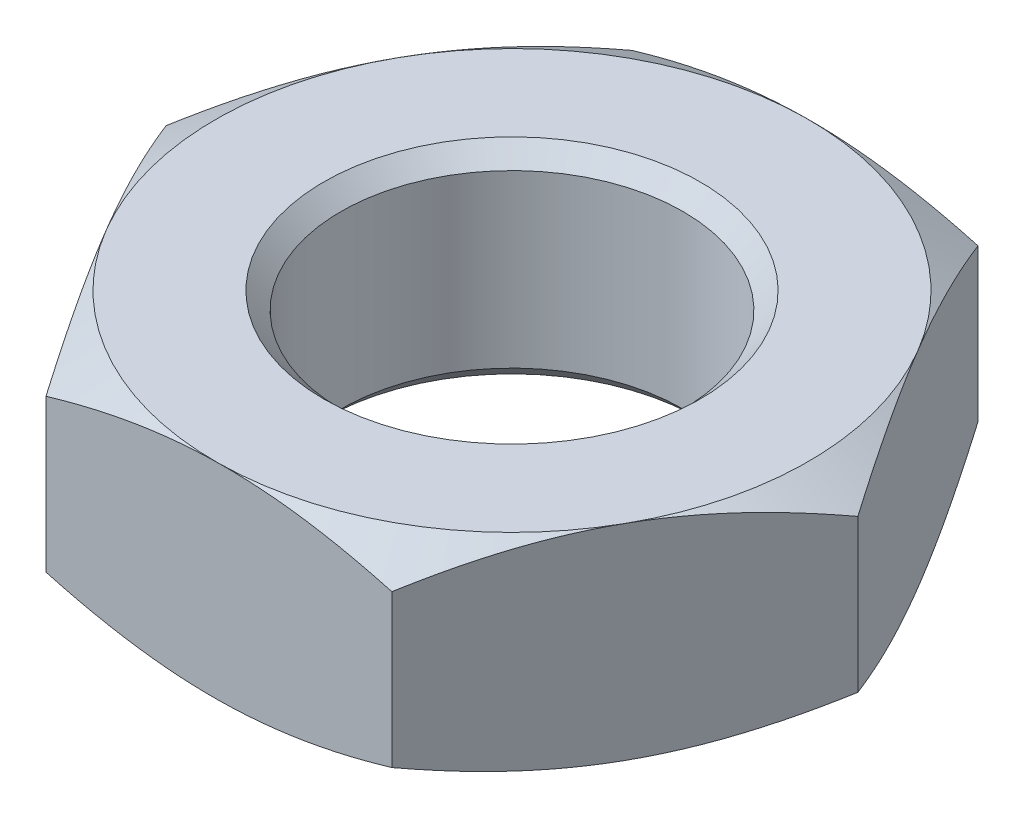
from build123d import *

# Parameters (mm, degrees)
SKETCH1_R           = 5
BOSS_EXTRUDE1_DEPTH = 3
CHAMFER1_SIZE       = 0.5
SKETCH2_OUTSIDE_W   = 62.08
SKETCH2_OUTSIDE_H   = 59.51
SKETCH2_OUTSIDE_R   = 8.660766964
CUT_EXTRUDE1_DEPTH  = 10
CUT_EXTRUDE1_TAPER  = 60


with BuildPart() as part:
    # Sketch1 → Boss-Extrude1 (new body, symmetric)
    with BuildSketch(Plane(origin=(0, 0, 0), x_dir=(1, 0, 0), z_dir=(0, 1, 0))):
        Polygon((-4.905742916, -8.714673391), (5.094257084, -8.605834685), (10, 0.108838706), (4.905742916, 8.714673391), (-5.094257084, 8.605834685), (-10, -0.108838706), align=None)
        Circle(SKETCH1_R, mode=Mode.SUBTRACT)
    extrude(amount=BOSS_EXTRUDE1_DEPTH, both=True)

    # Chamfer1
    chamfer1_edges = [part.edges().sort_by_distance(p)[0] for p in [
        (-5, -3, 0),
        (-5, 3, 0),
    ]]
    chamfer(chamfer1_edges, length=CHAMFER1_SIZE)

    # Sketch2 outside → Cut-Extrude1 (cut)
    with BuildSketch(Plane(origin=(0, 3, 0), x_dir=(1, 0, 0), z_dir=(0, 1, 0))):
        Rectangle(SKETCH2_OUTSIDE_W, SKETCH2_OUTSIDE_H)
        Circle(SKETCH2_OUTSIDE_R, mode=Mode.SUBTRACT)
    cut_extrude1 = extrude(amount=-CUT_EXTRUDE1_DEPTH, taper=CUT_EXTRUDE1_TAPER, mode=Mode.SUBTRACT)

    # Mirror1: Cut-Extrude1 across plane
    add(cut_extrude1.mirror(Plane.ZX), mode=Mode.SUBTRACT)


solid = part.part
